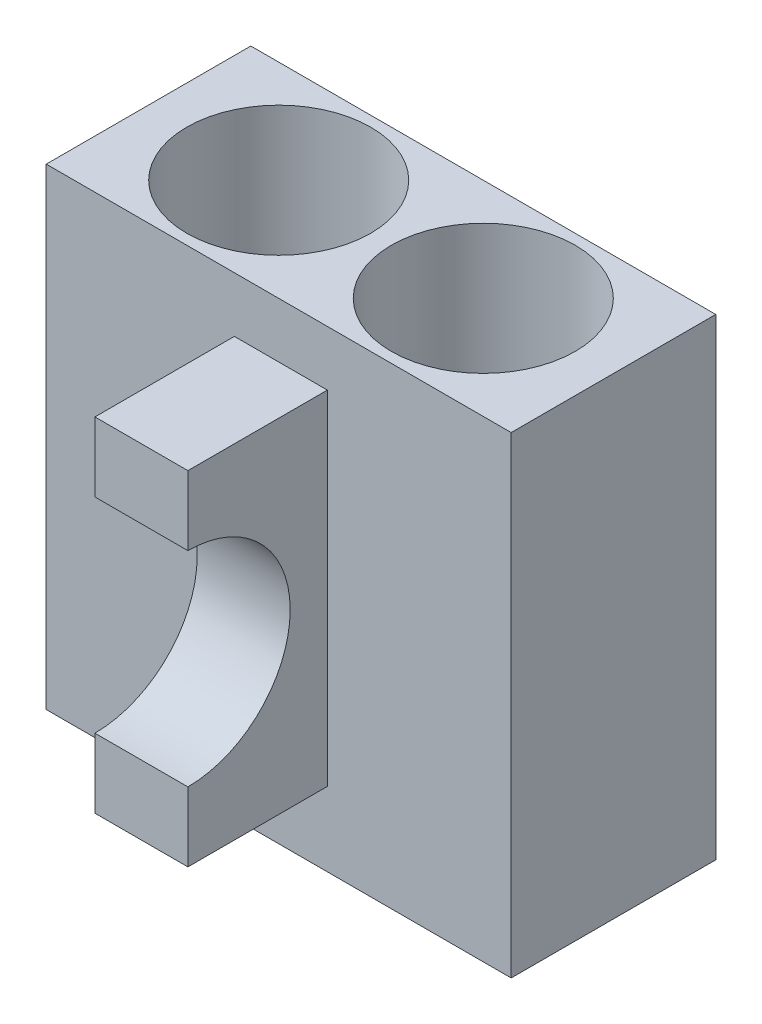
from build123d import *

# Parameters (mm, degrees)
SKETCH1_W           = 50
SKETCH1_H           = 22
SKETCH1_R           = 9.89
BOSS_EXTRUDE1_DEPTH = 50.8
SKETCH2_R           = 10.5
BOSS_EXTRUDE2_DEPTH = 1
SKETCH3_R           = 10.5
BOSS_EXTRUDE3_DEPTH = 6.35
SKETCH5_W           = 10
SKETCH5_H           = 36.91
BOSS_EXTRUDE4_DEPTH = 15
SKETCH7_R           = 11
CUT_EXTRUDE1_DEPTH  = 10


with BuildPart() as part:
    # Sketch1 → Boss-Extrude1 (new body)
    with BuildSketch(Plane(origin=(0, 0, 0), x_dir=(1, 0, 0), z_dir=(0, 1, 0))):
        with Locations((4.998255194, -0.2362853)):
            Rectangle(SKETCH1_W, SKETCH1_H)
        with Locations((-6.001744806, -0.2362853)):
            Circle(SKETCH1_R, mode=Mode.SUBTRACT)
        with Locations((15.998255194, -0.2362853)):
            Circle(SKETCH1_R, mode=Mode.SUBTRACT)
    extrude(amount=BOSS_EXTRUDE1_DEPTH)

    # Sketch2 → Boss-Extrude2 (add)
    with BuildSketch(Plane(origin=(0, 0, 0), x_dir=(1, 0, 0), z_dir=(0, 1, 0))):
        with Locations((15.998255194, -0.2362853)):
            Circle(SKETCH2_R)
        with Locations((-6.001744806, -0.2362853)):
            Circle(SKETCH2_R)
    extrude(amount=BOSS_EXTRUDE2_DEPTH)

    # Sketch3 → Boss-Extrude3 (add)
    with BuildSketch(Plane(origin=(0, 1, 0), x_dir=(1, 0, 0), z_dir=(0, 1, 0))):
        with Locations((15.703735374, 0)):
            Circle(SKETCH3_R)
    extrude(amount=BOSS_EXTRUDE3_DEPTH)

    # Sketch5 → Boss-Extrude4 (add)
    with BuildSketch(Plane.XY.offset(11.2362853)):
        with Locations((5.231381217, 26.416579834)):
            Rectangle(SKETCH5_W, SKETCH5_H)
    extrude(amount=BOSS_EXTRUDE4_DEPTH)

    # Sketch7 → Cut-Extrude1 (cut)
    with BuildSketch(Plane(origin=(10.231381217, 0, 0), x_dir=(0, 0, -1), z_dir=(1, 0, 0))):
        with Locations((-26.2362853, 26.416579834)):
            Circle(SKETCH7_R)
    extrude(amount=-CUT_EXTRUDE1_DEPTH, mode=Mode.SUBTRACT)


solid = part.part
